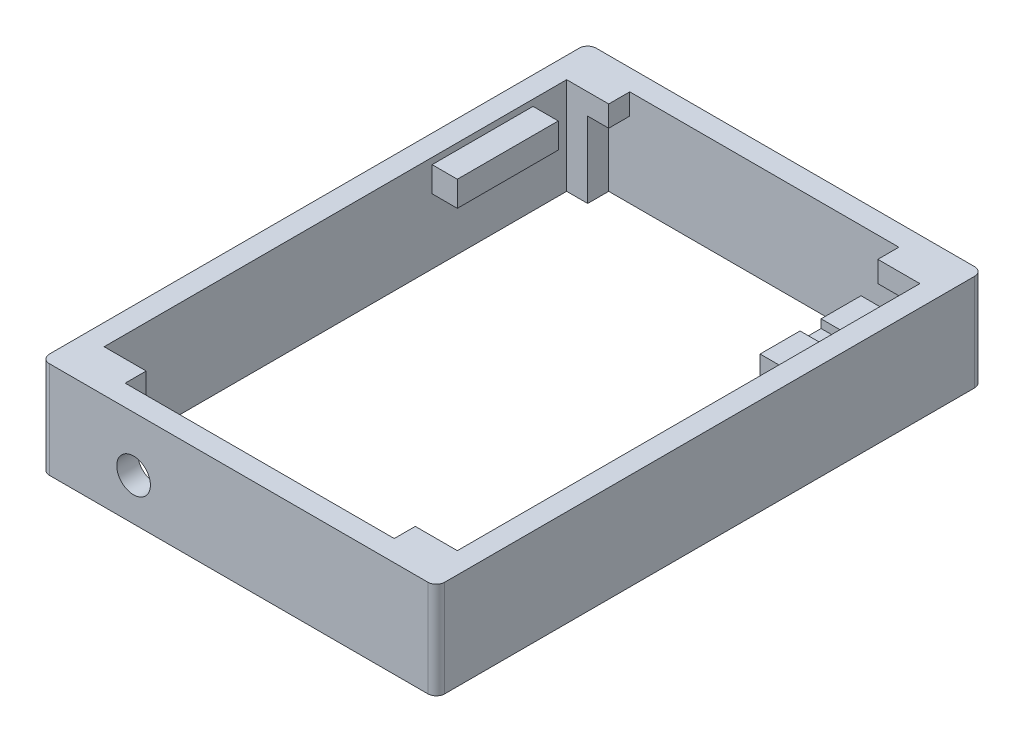
from build123d import *

# Parameters (mm, degrees)
SKETCH1_W            = 94
SKETCH1_H            = 130
BOSS_EXTRUDE1_DEPTH  = 23
SKETCH3_W            = 24
SKETCH3_H            = 6
BOSS_EXTRUDE2_DEPTH  = 6
SKETCH4_W            = 6
SKETCH4_H            = 5
CUT_EXTRUDE1_DEPTH   = 2
SKETCH5_W            = 5
SKETCH5_H            = 5
CUT_EXTRUDE2_DEPTH   = 18
LPATTERN1_COUNT      = 2
LPATTERN1_PITCH      = 69
LPATTERN1_COUNT_DIR2 = 2
LPATTERN1_PITCH_DIR2 = 115
FILLET1_R            = 2
SKETCH6_R            = 4
CUT_EXTRUDE3_DEPTH   = 7


with BuildPart() as part:
    # Sketch1 → Boss-Extrude1 (new body)
    with BuildSketch(Plane(origin=(0, 0, 0), x_dir=(1, 0, 0), z_dir=(0, 1, 0))):
        with Locations((47, 65)):
            Rectangle(SKETCH1_W, SKETCH1_H)
        Polygon((79, 125), (79, 120), (89, 120), (89, 10), (79, 10), (79, 5), (15, 5), (15, 10), (5, 10), (5, 120), (15, 120), (15, 125), align=None, mode=Mode.SUBTRACT)
    extrude(amount=BOSS_EXTRUDE1_DEPTH)

    # Sketch3 → Boss-Extrude2 (add)
    with BuildSketch(Plane(origin=(5, 0, 0), x_dir=(0, 0, -1), z_dir=(1, 0, 0))):
        with Locations((100, 18.5)):
            Rectangle(SKETCH3_W, SKETCH3_H)
    boss_extrude2 = extrude(amount=BOSS_EXTRUDE2_DEPTH)

    # Mirror3: Boss-Extrude2 across plane
    add(boss_extrude2.mirror(Plane.ZY.offset(-47)))

    # Sketch4 → Cut-Extrude1 (cut)
    with BuildSketch(Plane(origin=(0, 21.5, 0), x_dir=(1, 0, 0), z_dir=(0, 1, 0))):
        with Locations((86, 100)):
            Rectangle(SKETCH4_W, SKETCH4_H)
    extrude(amount=-CUT_EXTRUDE1_DEPTH, mode=Mode.SUBTRACT)

    # Sketch5 → Cut-Extrude2 (cut)
    with BuildSketch(Plane.XZ):
        with Locations((81.5, -122.5)):
            Rectangle(SKETCH5_W, SKETCH5_H)
    cut_extrude2 = extrude(amount=-CUT_EXTRUDE2_DEPTH, mode=Mode.SUBTRACT)

    # LPattern1: Cut-Extrude2 2 × 2
    with Locations(*[(-i * LPATTERN1_PITCH, 0, j * LPATTERN1_PITCH_DIR2) for i in range(LPATTERN1_COUNT) for j in range(LPATTERN1_COUNT_DIR2) if (i, j) != (0, 0)]):
        add(cut_extrude2, mode=Mode.SUBTRACT)

    # Fillet1
    fillet1_edges = [part.edges().sort_by_distance(p)[0] for p in [
        (0, 11.5, -130),
        (94, 11.5, -130),
        (94, 11.5, 0),
        (0, 11.5, 0),
    ]]
    fillet(fillet1_edges, radius=FILLET1_R)

    # Sketch6 → Cut-Extrude3 (cut)
    with BuildSketch(Plane.XY):
        with Locations((22, 10)):
            Circle(SKETCH6_R)
    extrude(amount=-CUT_EXTRUDE3_DEPTH, mode=Mode.SUBTRACT)


solid = part.part
